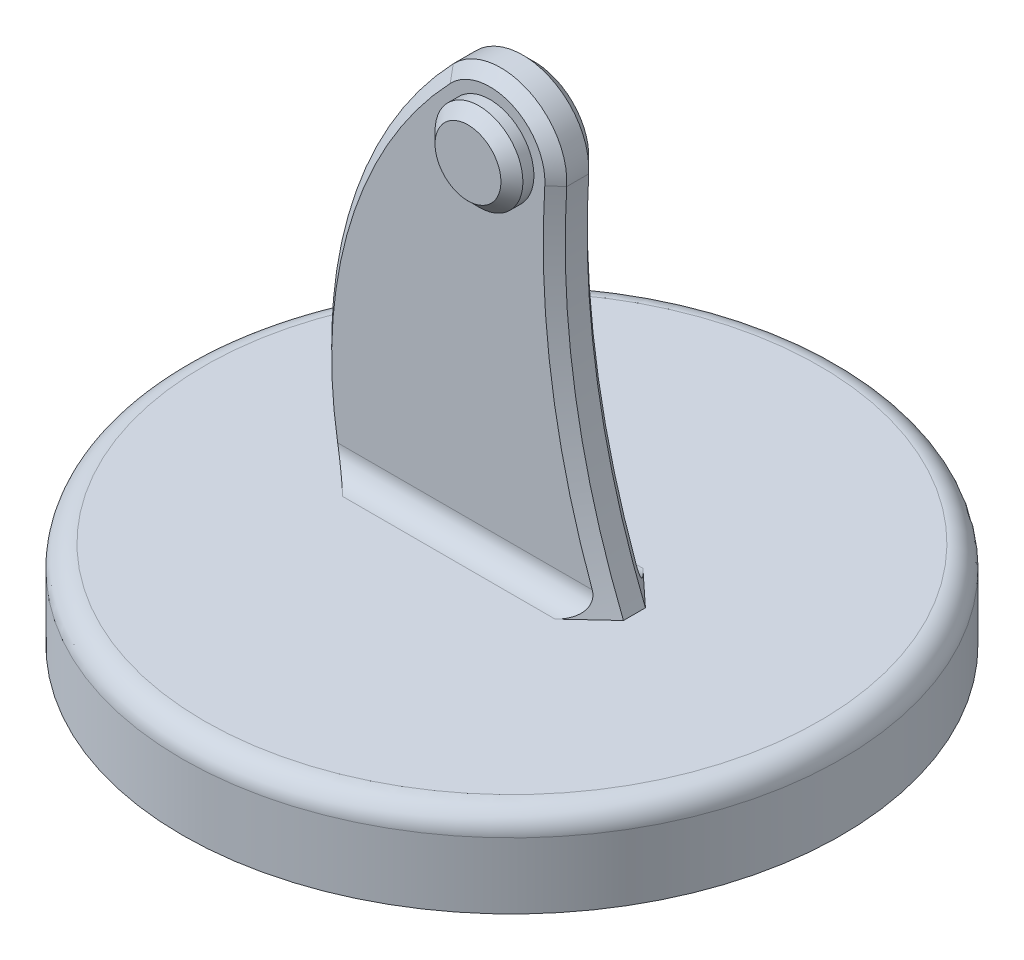
from build123d import *

# Parameters (mm, degrees)
SKETCH1_R           = 75
BOSS_EXTRUDE1_DEPTH = 20
FILLET3_R           = 5
BOSS_EXTRUDE2_DEPTH = 5
CHAMFER1_SIZE       = 2.5
FILLET4_R           = 5
SKETCH4_R           = 10
BOSS_EXTRUDE3_DEPTH = 5
CHAMFER2_SIZE       = 2.5
SKETCH5_R           = 5
CUT_EXTRUDE1_DEPTH  = 10


with BuildPart() as part:
    # Sketch1 → Boss-Extrude1 (new body)
    with BuildSketch(Plane(origin=(0, 0, 0), x_dir=(1, 0, 0), z_dir=(0, 1, 0))):
        Circle(SKETCH1_R)
    extrude(amount=BOSS_EXTRUDE1_DEPTH)

    # Fillet3
    fillet3_edges = [part.edges().sort_by_distance(p)[0] for p in [
        (-75, 20, 0),
    ]]
    fillet(fillet3_edges, radius=FILLET3_R)

    # Sketch3 → Boss-Extrude2 (add, symmetric)
    with BuildSketch(Plane.XY):
        with BuildLine():
            Line((-35, 15), (30, 15))
            ThreePointArc((30, 15), (17.428098582, 56.126843631), (14.970645506, 99.06203778))
            ThreePointArc((14.970645506, 99.06203778), (6.012327577, 113.742340307), (-10.849201429, 110.358321696))
            ThreePointArc((-10.849201429, 110.358321696), (-35.460543036, 65.854059614), (-35, 15))
        make_face()
    extrude(amount=BOSS_EXTRUDE2_DEPTH, both=True)

    # Chamfer1
    chamfer1_edges = [part.edges().sort_by_distance(p)[0] for p in [
        (-34.796467261, 68.341174934, -5),
        (16.970295051, 58.803839559, -5),
        (6.012327577, 113.742340307, -5),
        (16.970295051, 58.803839559, 5),
        (6.012327577, 113.742340307, 5),
        (-34.796467261, 68.341174934, 5),
    ]]
    chamfer(chamfer1_edges, length=CHAMFER1_SIZE)

    # Fillet4
    fillet4_edges = [part.edges().sort_by_distance(p)[0] for p in [
        (-4.241511046, 20, -5),
        (-4.241511046, 20, 5),
    ]]
    fillet(fillet4_edges, radius=FILLET4_R)

    # Sketch4 → Boss-Extrude3 (add)
    with BuildSketch(Plane.XY.offset(5)):
        with Locations((0, 100)):
            Circle(SKETCH4_R)
    extrude(amount=BOSS_EXTRUDE3_DEPTH)

    # Chamfer2
    chamfer2_edges = [part.edges().sort_by_distance(p)[0] for p in [
        (-10, 100, 10),
    ]]
    chamfer(chamfer2_edges, length=CHAMFER2_SIZE)

    # Sketch5 → Cut-Extrude1 (cut)
    with BuildSketch(Plane(origin=(0, 0, -5), x_dir=(-1, 0, 0), z_dir=(0, 0, -1))):
        with Locations((0, 100)):
            Circle(SKETCH5_R)
    extrude(amount=-CUT_EXTRUDE1_DEPTH, mode=Mode.SUBTRACT)


solid = part.part
